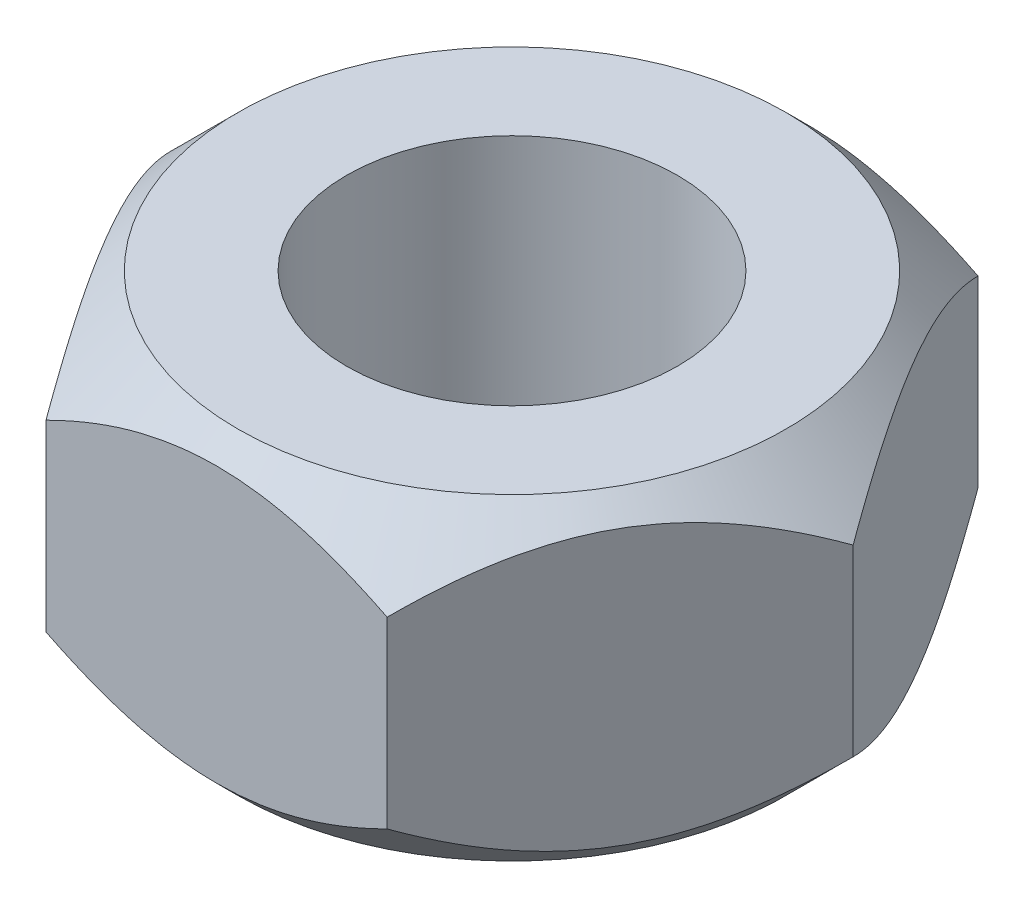
from build123d import *

# Parameters (mm, degrees)
SKETCH1_R         = 3.1115
EXTRUDE1_DEPTH    = 2.9845
SKETCH2_OUTSIDE_W = 30.368
SKETCH2_OUTSIDE_H = 28.648
SKETCH2_OUTSIDE_R = 5.1562
EXTRUDE2_DEPTH    = 5.969
EXTRUDE2_TAPER    = 45


with BuildPart() as part:
    # Sketch1 → Extrude1 (new body, symmetric)
    with BuildSketch(Plane(origin=(0, 0, 0), x_dir=(1, 0, 0), z_dir=(0, 1, 0))):
        Polygon((-3.207902433, 5.55625), (-6.415804866, 0), (-3.207902433, -5.55625), (3.207902433, -5.55625), (6.415804866, 0), (3.207902433, 5.55625), align=None)
        Circle(SKETCH1_R, mode=Mode.SUBTRACT)
    extrude(amount=EXTRUDE1_DEPTH, both=True)

    # Sketch2 outside → Extrude2 (cut)
    with BuildSketch(Plane(origin=(0, 2.9845, 0), x_dir=(1, 0, 0), z_dir=(0, 1, 0))):
        Rectangle(SKETCH2_OUTSIDE_W, SKETCH2_OUTSIDE_H)
        Circle(SKETCH2_OUTSIDE_R, mode=Mode.SUBTRACT)
    extrude2 = extrude(amount=-EXTRUDE2_DEPTH, taper=EXTRUDE2_TAPER, mode=Mode.SUBTRACT)

    # Mirror1: Extrude2 across plane
    add(extrude2.mirror(Plane.ZX), mode=Mode.SUBTRACT)


solid = part.part
